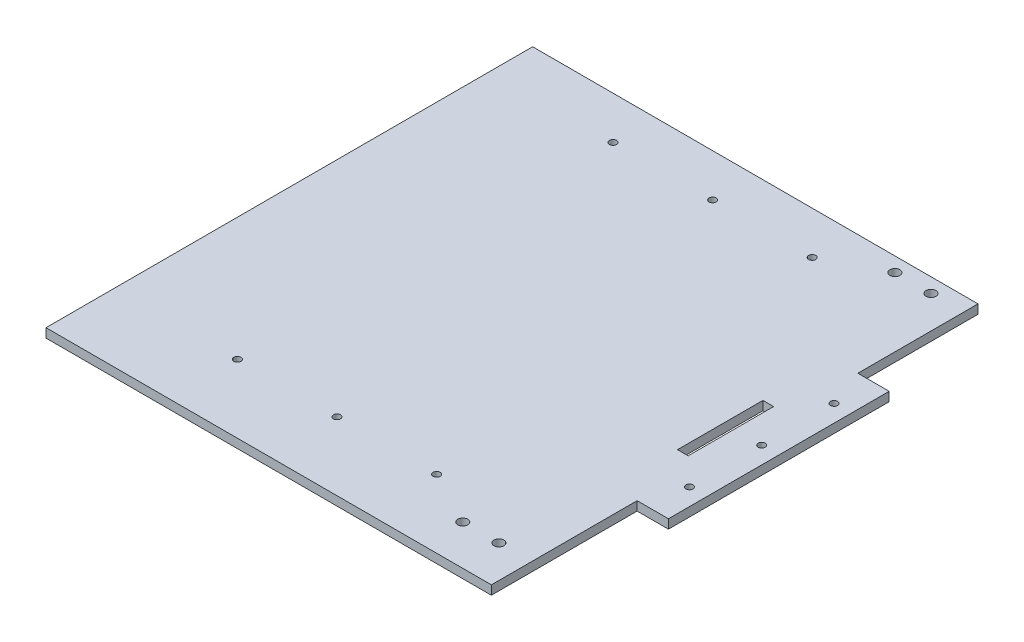
from build123d import *

# Parameters (mm, degrees)
SKETCH1_W           = 313
SKETCH1_H           = 342
BOSS_EXTRUDE1_DEPTH = 6.35
SKETCH3_W           = 22
SKETCH3_H           = 155.14040353
SKETCH3_R           = 2.5
BOSS_EXTRUDE2_DEPTH = 6.35
SKETCH2_R           = 2.5
CUT_EXTRUDE1_DEPTH  = 7.35
SKETCH4_R           = 3.5
CUT_EXTRUDE2_DEPTH  = 7.35
CUT_EXTRUDE3_DEPTH  = 7.35


with BuildPart() as part:
    # Sketch1 → Boss-Extrude1 (new body)
    with BuildSketch(Plane(origin=(0, 0, 0), x_dir=(1, 0, 0), z_dir=(0, 1, 0))):
        Rectangle(SKETCH1_W, SKETCH1_H)
    extrude(amount=-BOSS_EXTRUDE1_DEPTH)

    # Sketch3 → Boss-Extrude2 (add)
    with BuildSketch(Plane(origin=(0, 0, 0), x_dir=(1, 0, 0), z_dir=(0, 1, 0))):
        with Locations((167.5, 9)):
            Rectangle(SKETCH3_W, SKETCH3_H)
        with Locations((166.5, 9)):
            Circle(SKETCH3_R, mode=Mode.SUBTRACT)
        with Locations((166.5, -41.8)):
            Circle(SKETCH3_R, mode=Mode.SUBTRACT)
        with Locations((166.5, 59.8)):
            Circle(SKETCH3_R, mode=Mode.SUBTRACT)
    extrude(amount=-BOSS_EXTRUDE2_DEPTH)

    # Sketch2 → Cut-Extrude1 (cut, through all)
    with BuildSketch(Plane(origin=(0, 0, 0), x_dir=(1, 0, 0), z_dir=(0, 1, 0))):
        with Locations((0, -123)):
            Circle(SKETCH2_R)
        with Locations((-70, -123)):
            Circle(SKETCH2_R)
        with Locations((70, -123)):
            Circle(SKETCH2_R)
        with Locations((-70, 141)):
            Circle(SKETCH2_R)
        with Locations((0, 141)):
            Circle(SKETCH2_R)
        with Locations((70, 141)):
            Circle(SKETCH2_R)
    extrude(amount=-CUT_EXTRUDE1_DEPTH, mode=Mode.SUBTRACT)

    # Sketch4 → Cut-Extrude2 (cut, through all)
    with BuildSketch(Plane(origin=(0, 0, 0), x_dir=(1, 0, 0), z_dir=(0, 1, 0))):
        with Locations((133.64, 160.84)):
            Circle(SKETCH4_R)
        with Locations((108.24, 160.84)):
            Circle(SKETCH4_R)
    cut_extrude2 = extrude(amount=-CUT_EXTRUDE2_DEPTH, mode=Mode.SUBTRACT)

    # Mirror1: Cut-Extrude2 across plane
    add(cut_extrude2.mirror(Plane(origin=(0, 0, -9), x_dir=(1, 0, 0), z_dir=(0, 0, -1))), mode=Mode.SUBTRACT)

    # Sketch5 → Cut-Extrude3 (cut, through all)
    with BuildSketch(Plane(origin=(0, 0, 0), x_dir=(1, 0, 0), z_dir=(0, 1, 0))):
        Polygon((139.671773243, 36.673783491), (147.171773243, 36.673783491), (147.143523721, -23.326216509), (139.643523721, -23.326216509), align=None)
    extrude(amount=-CUT_EXTRUDE3_DEPTH, mode=Mode.SUBTRACT)


solid = part.part
